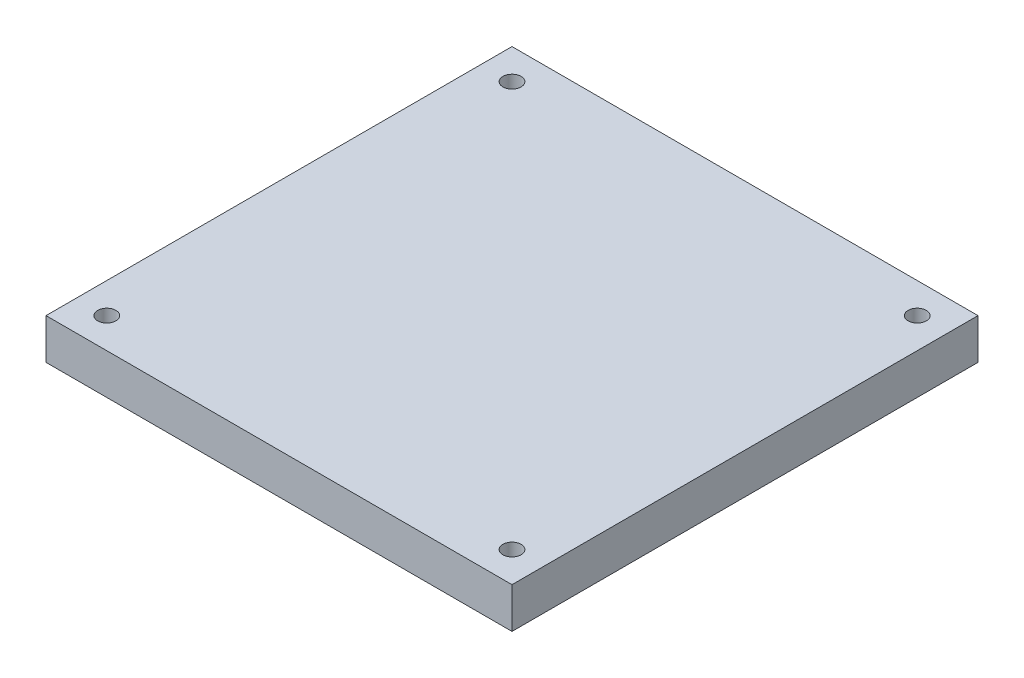
from build123d import *

# Parameters (mm, degrees)
SKETCH2_W           = 115
SKETCH2_H           = 115
SKETCH2_R           = 2.25
BOSS_EXTRUDE1_DEPTH = 10


with BuildPart() as part:
    # Sketch2 → Boss-Extrude1 (new body)
    with BuildSketch(Plane(origin=(0, 0, 0), x_dir=(1, 0, 0), z_dir=(0, 1, 0))):
        with Locations((57.5, 57.5)):
            Rectangle(SKETCH2_W, SKETCH2_H)
        with Locations((7.5, 7.5)):
            Circle(SKETCH2_R, mode=Mode.SUBTRACT)
        with Locations((107.5, 7.5)):
            Circle(SKETCH2_R, mode=Mode.SUBTRACT)
        with Locations((107.5, 107.5)):
            Circle(SKETCH2_R, mode=Mode.SUBTRACT)
        with Locations((7.5, 107.5)):
            Circle(SKETCH2_R, mode=Mode.SUBTRACT)
    extrude(amount=BOSS_EXTRUDE1_DEPTH)


solid = part.part
